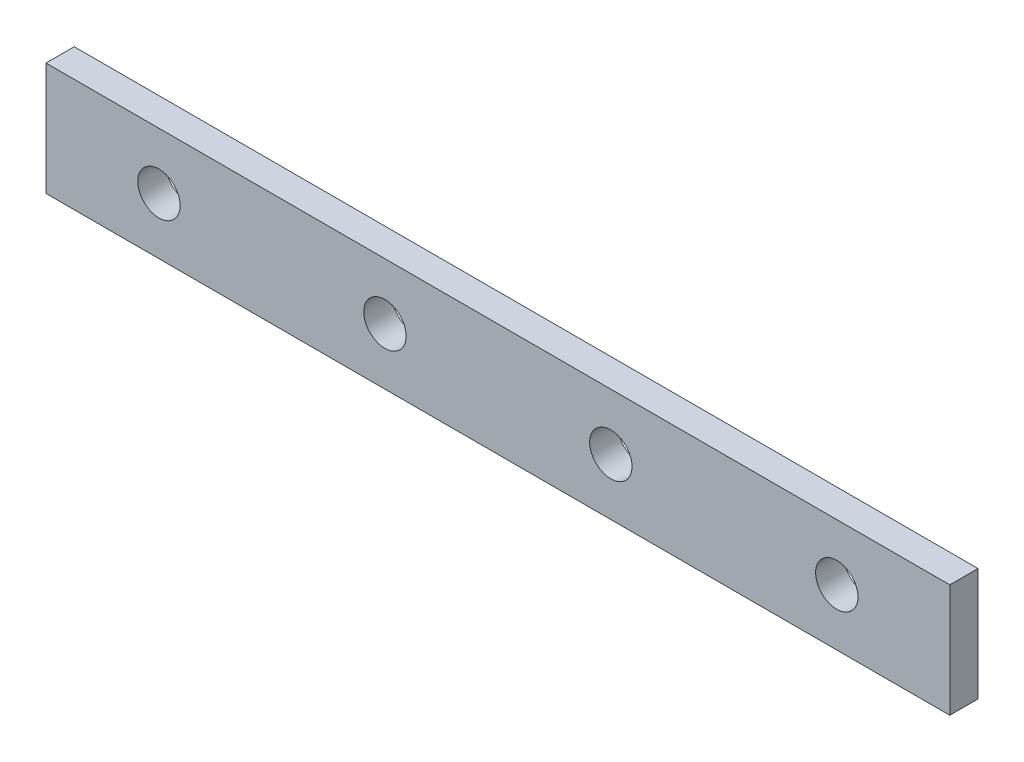
from build123d import *

# Parameters (mm, degrees)
SKETCH1_W           = 203.2
SKETCH1_H           = 25.4
BOSS_EXTRUDE1_DEPTH = 6.35
SKETCH2_R           = 4.7625
CUT_EXTRUDE1_DEPTH  = 7.35
LPATTERN1_COUNT     = 4
LPATTERN1_PITCH     = 50.8


with BuildPart() as part:
    # Sketch1 → Boss-Extrude1 (new body)
    with BuildSketch(Plane.XY):
        Rectangle(SKETCH1_W, SKETCH1_H)
    extrude(amount=BOSS_EXTRUDE1_DEPTH)

    # Sketch2 → Cut-Extrude1 (cut, through all)
    with BuildSketch(Plane.XY.offset(6.35)):
        with Locations((-76.2, 0)):
            Circle(SKETCH2_R)
    cut_extrude1 = extrude(amount=-CUT_EXTRUDE1_DEPTH, mode=Mode.SUBTRACT)

    # LPattern1: Cut-Extrude1 ×4
    with Locations(*[(i * LPATTERN1_PITCH, 0, 0) for i in range(1, LPATTERN1_COUNT)]):
        add(cut_extrude1, mode=Mode.SUBTRACT)


solid = part.part
